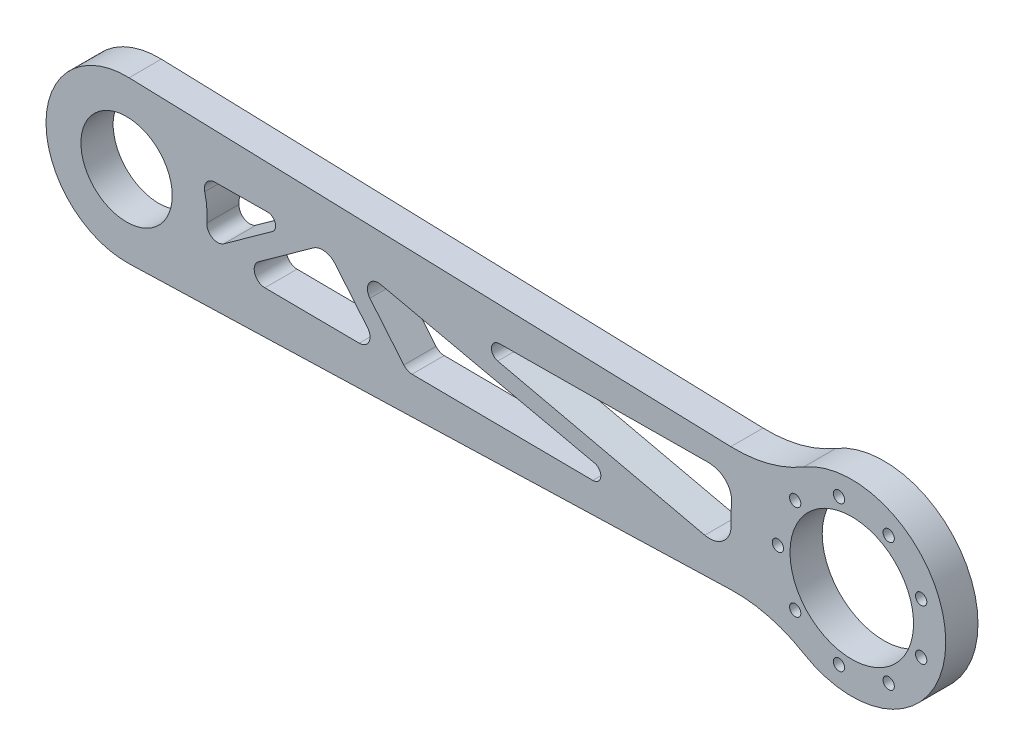
from build123d import *

# Parameters (mm, degrees)
EXTRUDE_1_DEPTH     = 12
SKETCH_2_R          = 17
CUT_EXTRUDE_1_DEPTH = 13
FILLET_1_R          = 50
SKETCH_6_R          = 2.1
CUT_EXTRUDE_5_DEPTH = 13
SKETCH_8_R          = 23
CUT_EXTRUDE_6_DEPTH = 13
CUT_EXTRUDE_7_DEPTH = 13
SKETCH_12_W         = 2.62725081
SKETCH_12_H         = 4.213047789
EXTRUDE_4_DEPTH     = 2
SKETCH_13_R         = 2.56677592
EXTRUDE_5_DEPTH     = 2


with BuildPart() as part:
    # 草图1 → 凸台-拉伸1 (new body)
    with BuildSketch(Plane.XY):
        with BuildLine():
            Line((0.926524708, 29.985689119), (243.190486763, 22.5))
            ThreePointArc((243.190486763, 22.5), (305, 0), (243.190486763, -22.5))
            Line((243.190486763, -22.5), (0.926524708, -29.985689119))
            ThreePointArc((0.926524708, -29.985689119), (-30, 0), (0.926524708, 29.985689119))
        make_face()
    extrude(amount=EXTRUDE_1_DEPTH)

    # 草图2 → 切除-拉伸1 (cut, through all)
    with BuildSketch(Plane.XY.offset(12)):
        Circle(SKETCH_2_R)
    extrude(amount=-CUT_EXTRUDE_1_DEPTH, mode=Mode.SUBTRACT)

    # 圆角1
    fillet_1_edges = [part.edges().sort_by_distance(p)[0] for p in [
        (243.190486763, 22.5, 6),
        (243.190486763, -22.5, 6),
    ]]
    fillet(fillet_1_edges, radius=FILLET_1_R)

    # 草图6 → 切除-拉伸5 (cut, through all)
    with BuildSketch(Plane(origin=(0, 0, 0), x_dir=(-1, 0, 0), z_dir=(0, 0, -1))):
        with Locations((-242.5, 0)):
            Circle(SKETCH_6_R)
        with Locations((-248.933777814, -17.676659266)):
            Circle(SKETCH_6_R)
        with Locations((-265.224675114, -27.082213208)):
            Circle(SKETCH_6_R)
        with Locations((-283.75, -23.815698604)):
            Circle(SKETCH_6_R)
        with Locations((-295.841547072, -9.405553941)):
            Circle(SKETCH_6_R)
        with Locations((-295.841547072, 9.405553941)):
            Circle(SKETCH_6_R)
        with Locations((-283.75, 23.815698604)):
            Circle(SKETCH_6_R)
        with Locations((-265.224675114, 27.082213208)):
            Circle(SKETCH_6_R)
        with Locations((-248.933777814, 17.676659266)):
            Circle(SKETCH_6_R)
    extrude(amount=-CUT_EXTRUDE_5_DEPTH, mode=Mode.SUBTRACT)

    # 草图8 → 切除-拉伸6 (cut, through all)
    with BuildSketch(Plane(origin=(0, 0, 0), x_dir=(-1, 0, 0), z_dir=(0, 0, -1))):
        with Locations((-270, 0)):
            Circle(SKETCH_8_R)
    extrude(amount=-CUT_EXTRUDE_6_DEPTH, mode=Mode.SUBTRACT)

    # 草图9 → 切除-拉伸7 (cut, through all)
    with BuildSketch(Plane.XY.offset(12)):
        with BuildLine():
            Line((138.177203146, 7.265958797), (215.280000441, -10.340469156))
            ThreePointArc((215.280000441, -10.340469156), (222.197122435, -8.67472562), (225.051756781, -2.157644912))
            ThreePointArc((225.051756781, -2.157644912), (225.019683108, 1.330823929), (225.25794544, 4.811294392))
            ThreePointArc((225.25794544, 4.811294392), (223.604832456, 10.595836396), (218.388318749, 13.592783755))
            ThreePointArc((218.388318749, 13.592783755), (217.739691011, 13.685144373), (217.09211046, 13.784582076))
            Line((217.09211046, 13.784582076), (138.82229573, 13.190588508))
            ThreePointArc((138.82229573, 13.190588508), (135.862688972, 10.515405209), (138.177203146, 7.265958797))
        make_face()
        with BuildLine():
            Line((32.937456826, 12.295827459), (52.445209699, 12.46606904))
            ThreePointArc((52.445209699, 12.46606904), (55.323007544, 10.397995174), (54.221641474, 7.029665807))
            Line((54.221641474, 7.029665807), (36.230602759, -5.894048054))
            ThreePointArc((36.230602759, -5.894048054), (31.93419641, -6.130708054), (29.909058708, -2.334139502))
            ThreePointArc((29.909058708, -2.334139502), (29.893460188, 2.526071657), (29.093261442, 7.319982148))
            ThreePointArc((29.093261442, 7.319982148), (29.806984137, 10.741460671), (32.937456826, 12.295827459))
        make_face()
        with BuildLine():
            Line((51.481125102, -12.457655601), (86.617092144, -12.76428254))
            ThreePointArc((86.617092144, -12.76428254), (90.265824875, -10.479152721), (89.728149821, -6.207622039))
            Line((89.728149821, -6.207622039), (77.62420084, 8.354875892))
            ThreePointArc((77.62420084, 8.354875892), (73.771130602, 10.471180848), (69.509469202, 9.392691606))
            Line((69.509469202, 9.392691606), (49.182361686, -5.209117958))
            ThreePointArc((49.182361686, -5.209117958), (47.703176381, -9.666996809), (51.481125102, -12.457655601))
        make_face()
        with BuildLine():
            Line((103.223250725, -11.492707953), (90.577517941, 3.721620677))
            ThreePointArc((90.577517941, 3.721620677), (90.240211818, 8.363692898), (94.524430804, 10.18250504))
            Line((94.524430804, 10.18250504), (174.23015633, -7.595003002))
            ThreePointArc((174.23015633, -7.595003002), (176.557582723, -10.864575787), (173.550905727, -13.522942438))
            Line((173.550905727, -13.522942438), (106.264496118, -12.935742837))
            ThreePointArc((106.264496118, -12.935742837), (104.584684386, -12.549721733), (103.223250725, -11.492707953))
        make_face()
    extrude(amount=-CUT_EXTRUDE_7_DEPTH, mode=Mode.SUBTRACT)


with BuildPart() as body_2:
    # 草图12 → 凸台-拉伸4 (new body)
    with BuildSketch(Plane(origin=(0, 0, 0), x_dir=(0, 0, -1), z_dir=(1, 0, 0))):
        with Locations((1.313625405, 2.106523894)):
            Rectangle(SKETCH_12_W, SKETCH_12_H)
    extrude(amount=EXTRUDE_4_DEPTH)


with BuildPart() as body_3:
    # 草图13 → 凸台-拉伸5 (new body)
    with BuildSketch(Plane(origin=(0, 0, 0), x_dir=(0, 0, -1), z_dir=(1, 0, 0))):
        with Locations((-9.79748635, 0)):
            Circle(SKETCH_13_R)
    extrude(amount=EXTRUDE_5_DEPTH)


solid = part.part
